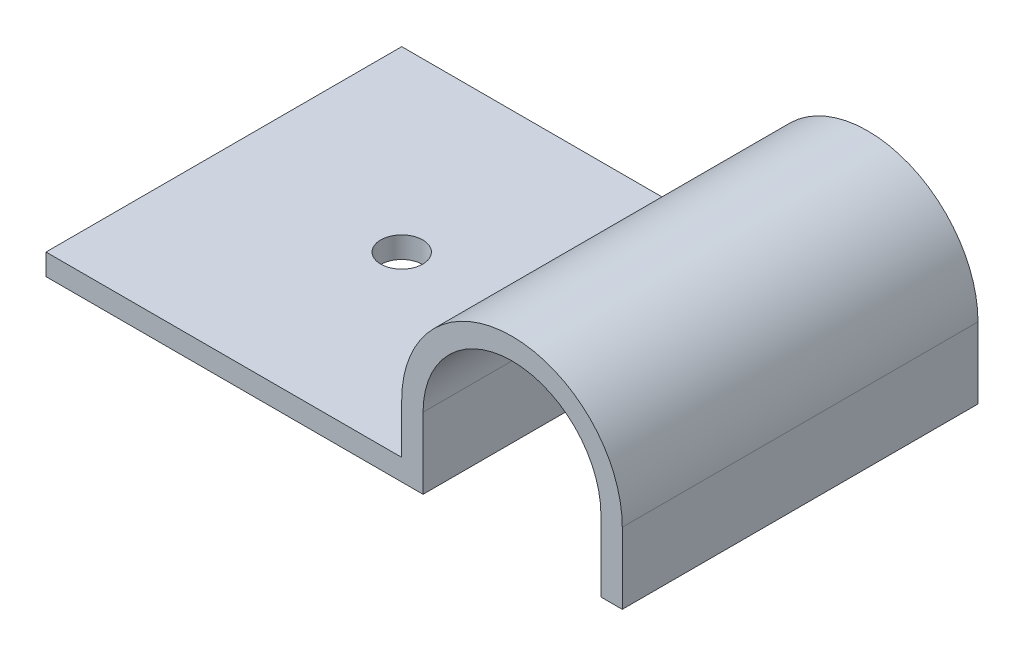
from build123d import *

# Parameters (mm, degrees)
BOSS_EXTRUDE1_DEPTH = 25.4
SKETCH2_W           = 25.4
SKETCH2_H           = 1.524
BOSS_EXTRUDE2_DEPTH = 25.4
SKETCH5_R           = 1.5
CUT_EXTRUDE1_DEPTH  = 2.54


with BuildPart() as part:
    # Sketch1 → Boss-Extrude1 (new body)
    with BuildSketch(Plane(origin=(0, 0, 0), x_dir=(-1, 0, 0), z_dir=(0, 0, -1))):
        with BuildLine():
            Line((7.9375, 2.8575), (9.4615, 2.8575))
            Line((9.4615, 2.8575), (9.4615, 7.9375))
            ThreePointArc((9.4615, 7.9375), (1.5875, 15.8115), (-6.2865, 7.9375))
            Line((-6.2865, 7.9375), (-6.2865, 2.8575))
            Line((-6.2865, 2.8575), (-4.7625, 2.8575))
            Line((-4.7625, 2.8575), (-4.7625, 7.9375))
            ThreePointArc((-4.7625, 7.9375), (1.5875, 14.2875), (7.9375, 7.9375))
            Line((7.9375, 7.9375), (7.9375, 2.8575))
        make_face()
    extrude(amount=-BOSS_EXTRUDE1_DEPTH)

    # Sketch2 → Boss-Extrude2 (add)
    with BuildSketch(Plane.ZY.offset(9.4615)):
        with Locations((12.7, 3.6195)):
            Rectangle(SKETCH2_W, SKETCH2_H)
    extrude(amount=BOSS_EXTRUDE2_DEPTH)

    # Sketch5 → Cut-Extrude1 (cut)
    with BuildSketch(Plane(origin=(0, 4.3815, 0), x_dir=(1, 0, 0), z_dir=(0, 1, 0))):
        with Locations((-22.1615, -12.7)):
            Circle(SKETCH5_R)
    extrude(amount=-CUT_EXTRUDE1_DEPTH, mode=Mode.SUBTRACT)


solid = part.part
